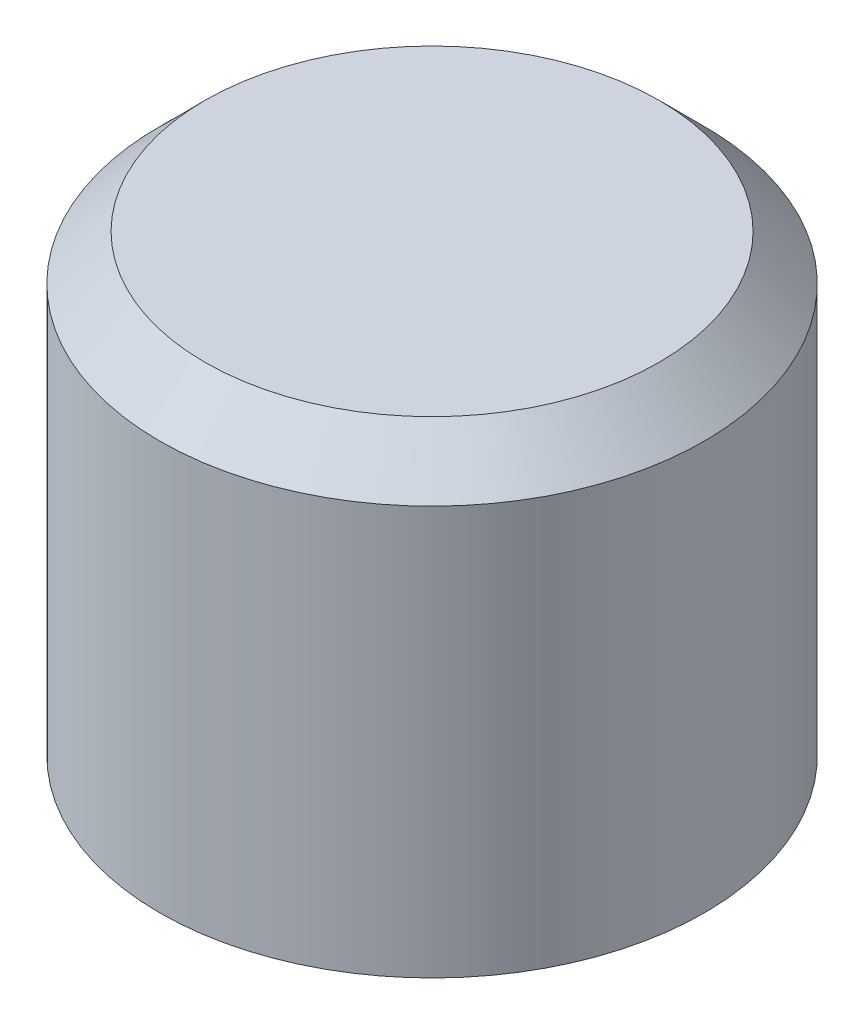
from build123d import *

# Parameters (mm, degrees)
SKETCH1_R           = 6
BOSS_EXTRUDE1_DEPTH = 10
CHAMFER1_SIZE       = 1
SKETCH2_R           = 4
CUT_EXTRUDE1_DEPTH  = 7


with BuildPart() as part:
    # Sketch1 → Boss-Extrude1 (new body)
    with BuildSketch(Plane(origin=(0, 0, 0), x_dir=(1, 0, 0), z_dir=(0, 1, 0))):
        Circle(SKETCH1_R)
    extrude(amount=BOSS_EXTRUDE1_DEPTH)

    # Chamfer1
    chamfer1_edges = [part.edges().sort_by_distance(p)[0] for p in [
        (-6, 10, 0),
    ]]
    chamfer(chamfer1_edges, length=CHAMFER1_SIZE)

    # Sketch2 → Cut-Extrude1 (cut)
    with BuildSketch(Plane.XZ):
        Circle(SKETCH2_R)
    extrude(amount=-CUT_EXTRUDE1_DEPTH, mode=Mode.SUBTRACT)


solid = part.part
